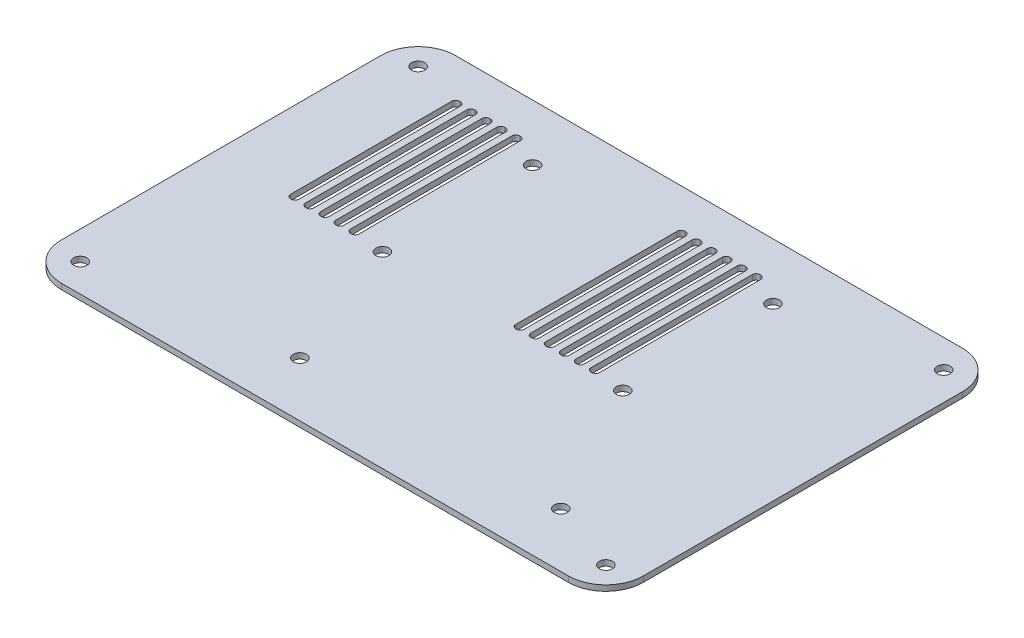
from build123d import *

# Parameters (mm, degrees)
SKETCH1_W           = 310
SKETCH1_H           = 210
SKETCH1_R           = 3.5
BOSS_EXTRUDE1_DEPTH = 3
FILLET1_R           = 20
CUT_EXTRUDE2_DEPTH  = 10


with BuildPart() as part:
    # Sketch1 → Boss-Extrude1 (new body)
    with BuildSketch(Plane(origin=(0, 0, 0), x_dir=(1, 0, 0), z_dir=(0, 1, 0))):
        Rectangle(SKETCH1_W, SKETCH1_H)
        with Locations((-140, 90)):
            Circle(SKETCH1_R, mode=Mode.SUBTRACT)
        with Locations((140, 90)):
            Circle(SKETCH1_R, mode=Mode.SUBTRACT)
        with Locations((140, -90)):
            Circle(SKETCH1_R, mode=Mode.SUBTRACT)
        with Locations((-140, -90)):
            Circle(SKETCH1_R, mode=Mode.SUBTRACT)
        with Locations((102, -76)):
            Circle(SKETCH1_R, mode=Mode.SUBTRACT)
        with Locations((-37, -76)):
            Circle(SKETCH1_R, mode=Mode.SUBTRACT)
        with Locations((-64, 75)):
            Circle(SKETCH1_R, mode=Mode.SUBTRACT)
        with Locations((64, 75)):
            Circle(SKETCH1_R, mode=Mode.SUBTRACT)
        with Locations((-64, -5)):
            Circle(SKETCH1_R, mode=Mode.SUBTRACT)
        with Locations((64, -5)):
            Circle(SKETCH1_R, mode=Mode.SUBTRACT)
    extrude(amount=BOSS_EXTRUDE1_DEPTH)

    # Fillet1
    fillet1_edges = [part.edges().sort_by_distance(p)[0] for p in [
        (-155, 1.5, -105),
        (155, 1.5, -105),
        (155, 1.5, 105),
        (-155, 1.5, 105),
    ]]
    fillet(fillet1_edges, radius=FILLET1_R)

    # Sketch2 → Cut-Extrude2 (cut)
    with BuildSketch(Plane(origin=(0, 3, 0), x_dir=(1, 0, 0), z_dir=(0, 1, 0))):
        with BuildLine():
            Line((-107, 83), (-107, -3))
            ThreePointArc((-107, -3), (-106.414213562, -4.414213562), (-105, -5))
            Line((-105, -5), (-104.5, -5))
            ThreePointArc((-104.5, -5), (-103.085786438, -4.414213562), (-102.5, -3))
            Line((-102.5, -3), (-102.5, 83))
            ThreePointArc((-102.5, 83), (-103.085786438, 84.414213562), (-104.5, 85))
            Line((-104.5, 85), (-105, 85))
            ThreePointArc((-105, 85), (-106.414213562, 84.414213562), (-107, 83))
        make_face()
        with BuildLine():
            Line((-113, 85), (-112.5, 85))
            ThreePointArc((-112.5, 85), (-111.085786438, 84.414213562), (-110.5, 83))
            Line((-110.5, 83), (-110.5, -3))
            ThreePointArc((-110.5, -3), (-111.085786438, -4.414213562), (-112.5, -5))
            Line((-112.5, -5), (-113, -5))
            ThreePointArc((-113, -5), (-114.414213562, -4.414213562), (-115, -3))
            Line((-115, -3), (-115, 83))
            ThreePointArc((-115, 83), (-114.414213562, 84.414213562), (-113, 85))
        make_face()
        with BuildLine():
            Line((-99, 83), (-99, -3))
            ThreePointArc((-99, -3), (-98.414213562, -4.414213562), (-97, -5))
            Line((-97, -5), (-96.5, -5))
            ThreePointArc((-96.5, -5), (-95.085786438, -4.414213562), (-94.5, -3))
            Line((-94.5, -3), (-94.5, 83))
            ThreePointArc((-94.5, 83), (-95.085786438, 84.414213562), (-96.5, 85))
            Line((-96.5, 85), (-97, 85))
            ThreePointArc((-97, 85), (-98.414213562, 84.414213562), (-99, 83))
        make_face()
        with BuildLine():
            Line((-91, 83), (-91, -3))
            ThreePointArc((-91, -3), (-90.414213562, -4.414213562), (-89, -5))
            Line((-89, -5), (-88.5, -5))
            ThreePointArc((-88.5, -5), (-87.085786438, -4.414213562), (-86.5, -3))
            Line((-86.5, -3), (-86.5, 83))
            ThreePointArc((-86.5, 83), (-87.085786438, 84.414213562), (-88.5, 85))
            Line((-88.5, 85), (-89, 85))
            ThreePointArc((-89, 85), (-90.414213562, 84.414213562), (-91, 83))
        make_face()
        with BuildLine():
            Line((-83, 83), (-83, -3))
            ThreePointArc((-83, -3), (-82.414213562, -4.414213562), (-81, -5))
            Line((-81, -5), (-80.5, -5))
            ThreePointArc((-80.5, -5), (-79.085786438, -4.414213562), (-78.5, -3))
            Line((-78.5, -3), (-78.5, 83))
            ThreePointArc((-78.5, 83), (-79.085786438, 84.414213562), (-80.5, 85))
            Line((-80.5, 85), (-81, 85))
            ThreePointArc((-81, 85), (-82.414213562, 84.414213562), (-83, 83))
        make_face()
        with BuildLine():
            Line((5, 83), (5, -3))
            ThreePointArc((5, -3), (5.585786438, -4.414213562), (7, -5))
            Line((7, -5), (7.5, -5))
            ThreePointArc((7.5, -5), (8.914213562, -4.414213562), (9.5, -3))
            Line((9.5, -3), (9.5, 83))
            ThreePointArc((9.5, 83), (8.914213562, 84.414213562), (7.5, 85))
            Line((7.5, 85), (7, 85))
            ThreePointArc((7, 85), (5.585786438, 84.414213562), (5, 83))
        make_face()
        with BuildLine():
            Line((13, 83), (13, -3))
            ThreePointArc((13, -3), (13.585786438, -4.414213562), (15, -5))
            Line((15, -5), (15.5, -5))
            ThreePointArc((15.5, -5), (16.914213562, -4.414213562), (17.5, -3))
            Line((17.5, -3), (17.5, 83))
            ThreePointArc((17.5, 83), (16.914213562, 84.414213562), (15.5, 85))
            Line((15.5, 85), (15, 85))
            ThreePointArc((15, 85), (13.585786438, 84.414213562), (13, 83))
        make_face()
        with BuildLine():
            Line((21, 83), (21, -3))
            ThreePointArc((21, -3), (21.585786438, -4.414213562), (23, -5))
            Line((23, -5), (23.5, -5))
            ThreePointArc((23.5, -5), (24.914213562, -4.414213562), (25.5, -3))
            Line((25.5, -3), (25.5, 83))
            ThreePointArc((25.5, 83), (24.914213562, 84.414213562), (23.5, 85))
            Line((23.5, 85), (23, 85))
            ThreePointArc((23, 85), (21.585786438, 84.414213562), (21, 83))
        make_face()
        with BuildLine():
            Line((29, 83), (29, -3))
            ThreePointArc((29, -3), (29.585786438, -4.414213562), (31, -5))
            Line((31, -5), (31.5, -5))
            ThreePointArc((31.5, -5), (32.914213562, -4.414213562), (33.5, -3))
            Line((33.5, -3), (33.5, 83))
            ThreePointArc((33.5, 83), (32.914213562, 84.414213562), (31.5, 85))
            Line((31.5, 85), (31, 85))
            ThreePointArc((31, 85), (29.585786438, 84.414213562), (29, 83))
        make_face()
        with BuildLine():
            Line((37, 83), (37, -3))
            ThreePointArc((37, -3), (37.585786438, -4.414213562), (39, -5))
            Line((39, -5), (39.5, -5))
            ThreePointArc((39.5, -5), (40.914213562, -4.414213562), (41.5, -3))
            Line((41.5, -3), (41.5, 83))
            ThreePointArc((41.5, 83), (40.914213562, 84.414213562), (39.5, 85))
            Line((39.5, 85), (39, 85))
            ThreePointArc((39, 85), (37.585786438, 84.414213562), (37, 83))
        make_face()
        with BuildLine():
            Line((45, 83), (45, -3))
            ThreePointArc((45, -3), (45.585786438, -4.414213562), (47, -5))
            Line((47, -5), (47.5, -5))
            ThreePointArc((47.5, -5), (48.914213562, -4.414213562), (49.5, -3))
            Line((49.5, -3), (49.5, 83))
            ThreePointArc((49.5, 83), (48.914213562, 84.414213562), (47.5, 85))
            Line((47.5, 85), (47, 85))
            ThreePointArc((47, 85), (45.585786438, 84.414213562), (45, 83))
        make_face()
    extrude(amount=-CUT_EXTRUDE2_DEPTH, mode=Mode.SUBTRACT)


solid = part.part
